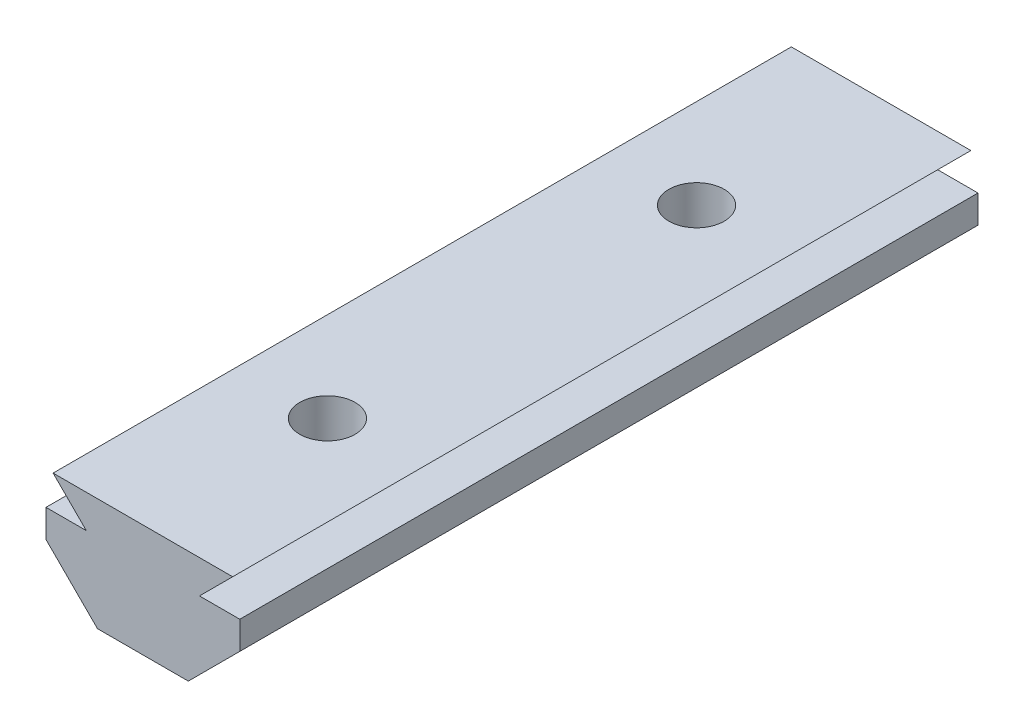
from build123d import *

# Parameters (mm, degrees)
BOSS_EXTRUDE1_DEPTH = 40
SKETCH2_R           = 1.5
CUT_EXTRUDE1_DEPTH  = 7.1
CUT_EXTRUDE3_DEPTH  = 3


with BuildPart() as part:
    # Sketch1 → Boss-Extrude1 (new body)
    with BuildSketch(Plane.XY):
        Polygon((-2.460653528, 0), (2.460653528, 0), (5.25, 2.789346472), (5.25, 4.3), (3.065, 4.3), (4.865, 6.1), (-4.865, 6.1), (-3.065, 4.3), (-5.25, 4.3), (-5.25, 2.789346472), align=None)
    extrude(amount=BOSS_EXTRUDE1_DEPTH)

    # Sketch2 → Cut-Extrude1 (cut, through all)
    with BuildSketch(Plane(origin=(0, 6.1, 0), x_dir=(1, 0, 0), z_dir=(0, 1, 0))):
        with Locations((0, -30)):
            Circle(SKETCH2_R)
        with Locations((0, -10)):
            Circle(SKETCH2_R)
    extrude(amount=-CUT_EXTRUDE1_DEPTH, mode=Mode.SUBTRACT)

    # Sketch5 → Cut-Extrude3 (cut)
    with BuildSketch(Plane(origin=(0, 0, 0), x_dir=(-1, 0, 0), z_dir=(0, -1, 0))):
        Polygon((-3.233161507, -10), (-1.616580754, -12.8), (1.616580754, -12.8), (3.233161507, -10), (1.616580754, -7.2), (-1.616580754, -7.2), align=None)
        Polygon((-3.233161507, -30), (-1.616580754, -32.8), (1.616580754, -32.8), (3.233161507, -30), (1.616580754, -27.2), (-1.616580754, -27.2), align=None)
    extrude(amount=-CUT_EXTRUDE3_DEPTH, mode=Mode.SUBTRACT)


solid = part.part
